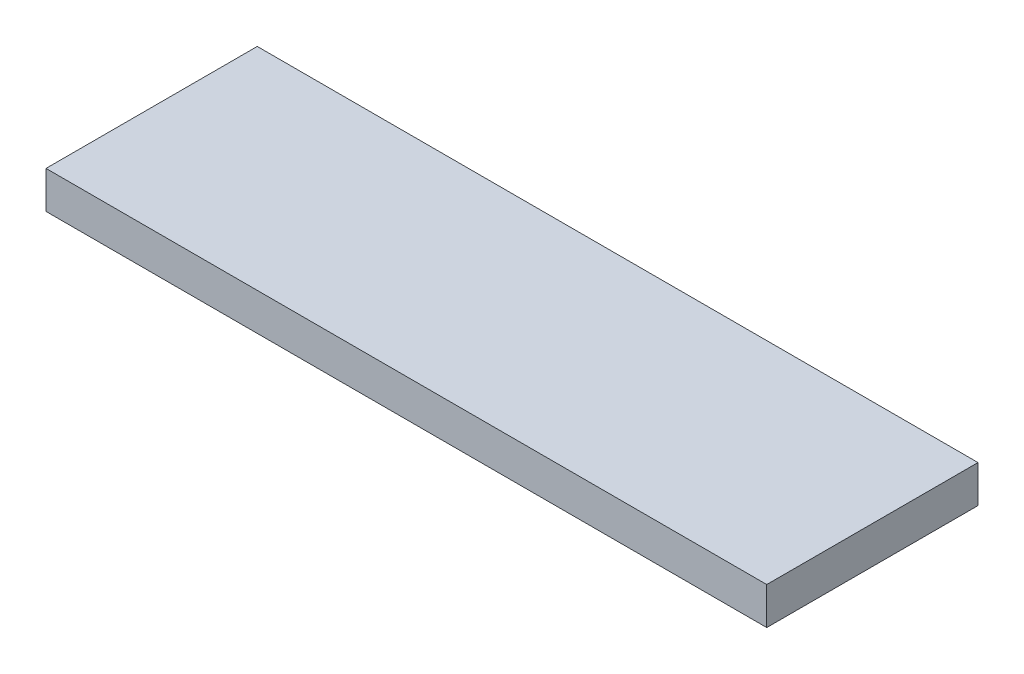
from build123d import *

# Parameters (mm, degrees)
SKETCH_1_W          = 1700
SKETCH_1_H          = 300
EXTRUDE_1_DEPTH     = 5800
SKETCH_2_W          = 1000
SKETCH_2_H          = 1200
CUT_EXTRUDE_1_DEPTH = 100
FILLET_1_R          = 40


with BuildPart() as part:
    # Эскиз1 → Бобышка-Вытянуть1 (new body)
    with BuildSketch(Plane(origin=(0, 0, 0), x_dir=(0, 0, -1), z_dir=(1, 0, 0))):
        with Locations((850, 150)):
            Rectangle(SKETCH_1_W, SKETCH_1_H)
    extrude(amount=EXTRUDE_1_DEPTH)

    # Эскиз2 → Вырез-Вытянуть1 (cut)
    with BuildSketch(Plane.XZ):
        with Locations((2250, -850)):
            Rectangle(SKETCH_2_W, SKETCH_2_H)
        with Locations((900, -850)):
            Rectangle(SKETCH_2_W, SKETCH_2_H)
        with Locations((3600, -850)):
            Rectangle(SKETCH_2_W, SKETCH_2_H)
        with Locations((4950, -850)):
            Rectangle(SKETCH_2_W, SKETCH_2_H)
    extrude(amount=-CUT_EXTRUDE_1_DEPTH, mode=Mode.SUBTRACT)

    # Скругление1
    fillet_1_edges = [part.edges().sort_by_distance(p)[0] for p in [
        (400, 100, -850),
    ]]
    fillet(fillet_1_edges, radius=FILLET_1_R)


solid = part.part
